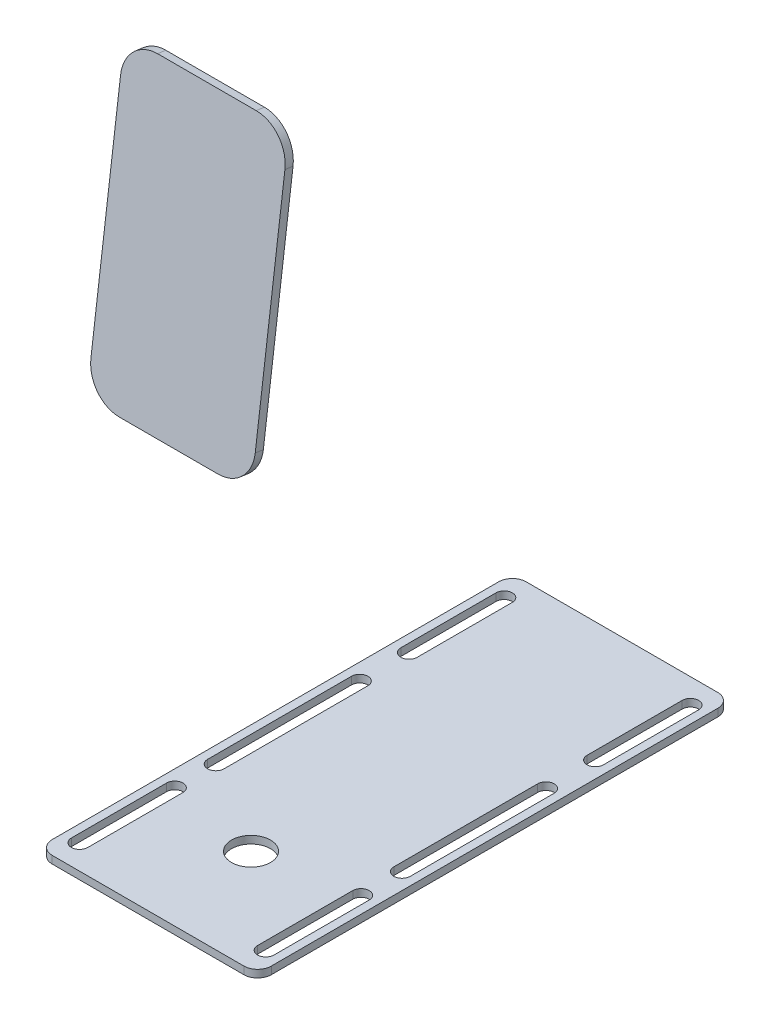
from build123d import *

# Parameters (mm, degrees)
SKETCH1_R           = 7.112045721
BOSS_EXTRUDE1_DEPTH = 2.75
BOSS_EXTRUDE2_DEPTH = 3


with BuildPart() as part:
    # Sketch1 → Boss-Extrude1 (new body)
    with BuildSketch(Plane(origin=(0, 0, 0), x_dir=(1, 0, 0), z_dir=(0, 1, 0))):
        with BuildLine():
            Line((-35, 86.51875), (35, 86.51875))
            ThreePointArc((35, 86.51875), (38.535533906, 85.054283906), (40, 81.51875))
            Line((40, 81.51875), (40, -81.51875))
            ThreePointArc((40, -81.51875), (38.535533906, -85.054283906), (35, -86.51875))
            Line((35, -86.51875), (-35, -86.51875))
            ThreePointArc((-35, -86.51875), (-38.535533906, -85.054283906), (-40, -81.51875))
            Line((-40, -81.51875), (-40, 81.51875))
            ThreePointArc((-40, 81.51875), (-38.535533906, 85.054283906), (-35, 86.51875))
        make_face()
        with Locations((0, -48.920084539)):
            Circle(SKETCH1_R, mode=Mode.SUBTRACT)
        with BuildLine():
            Line((37, 77.51875), (37, 42.76875))
            ThreePointArc((37, 42.76875), (34, 39.76875), (31, 42.76875))
            Line((31, 42.76875), (31, 77.51875))
            ThreePointArc((31, 77.51875), (34, 80.51875), (37, 77.51875))
        make_face(mode=Mode.SUBTRACT)
        with BuildLine():
            Line((-37, 77.51875), (-37, 42.76875))
            ThreePointArc((-37, 42.76875), (-34, 39.76875), (-31, 42.76875))
            Line((-31, 42.76875), (-31, 77.51875))
            ThreePointArc((-31, 77.51875), (-34, 80.51875), (-37, 77.51875))
        make_face(mode=Mode.SUBTRACT)
        with BuildLine():
            Line((37, -77.51875), (37, -42.76875))
            ThreePointArc((37, -42.76875), (34, -39.76875), (31, -42.76875))
            Line((31, -42.76875), (31, -77.51875))
            ThreePointArc((31, -77.51875), (34, -80.51875), (37, -77.51875))
        make_face(mode=Mode.SUBTRACT)
        with BuildLine():
            Line((-37, -77.51875), (-37, -42.76875))
            ThreePointArc((-37, -42.76875), (-34, -39.76875), (-31, -42.76875))
            Line((-31, -42.76875), (-31, -77.51875))
            ThreePointArc((-31, -77.51875), (-34, -80.51875), (-37, -77.51875))
        make_face(mode=Mode.SUBTRACT)
        with BuildLine():
            Line((37, 24.76875), (37, -27.76875))
            ThreePointArc((37, -27.76875), (34, -30.76875), (31, -27.76875))
            Line((31, -27.76875), (31, 24.76875))
            ThreePointArc((31, 24.76875), (34, 27.76875), (37, 24.76875))
        make_face(mode=Mode.SUBTRACT)
        with BuildLine():
            Line((-37, 24.76875), (-37, -27.76875))
            ThreePointArc((-37, -27.76875), (-34, -30.76875), (-31, -27.76875))
            Line((-31, -27.76875), (-31, 24.76875))
            ThreePointArc((-31, 24.76875), (-34, 27.76875), (-37, 24.76875))
        make_face(mode=Mode.SUBTRACT)
    extrude(amount=BOSS_EXTRUDE1_DEPTH)


with BuildPart() as body_2:
    # Sketch3 → Boss-Extrude2 (new body)
    with BuildSketch(Plane(origin=(0, 12.370657811, 96.117341263), x_dir=(0, -0.991819174, 0.127650801), z_dir=(0, 0.127650801, 0.991819174))):
        with BuildLine():
            Line((-231.622374558, 30), (-146.731557682, 30))
            ThreePointArc((-146.731557682, 30), (-138.246276308, 26.485281374), (-134.731557682, 18))
            Line((-134.731557682, 18), (-134.731557682, -18))
            ThreePointArc((-134.731557682, -18), (-138.246276308, -26.485281374), (-146.731557682, -30))
            Line((-146.731557682, -30), (-231.622374558, -30))
            ThreePointArc((-231.622374558, -30), (-240.107655932, -26.485281374), (-243.622374558, -18))
            Line((-243.622374558, -18), (-243.622374558, 18))
            ThreePointArc((-243.622374558, 18), (-240.107655932, 26.485281374), (-231.622374558, 30))
        make_face()
    extrude(amount=-BOSS_EXTRUDE2_DEPTH)


solid = Compound([part.part, body_2.part])
